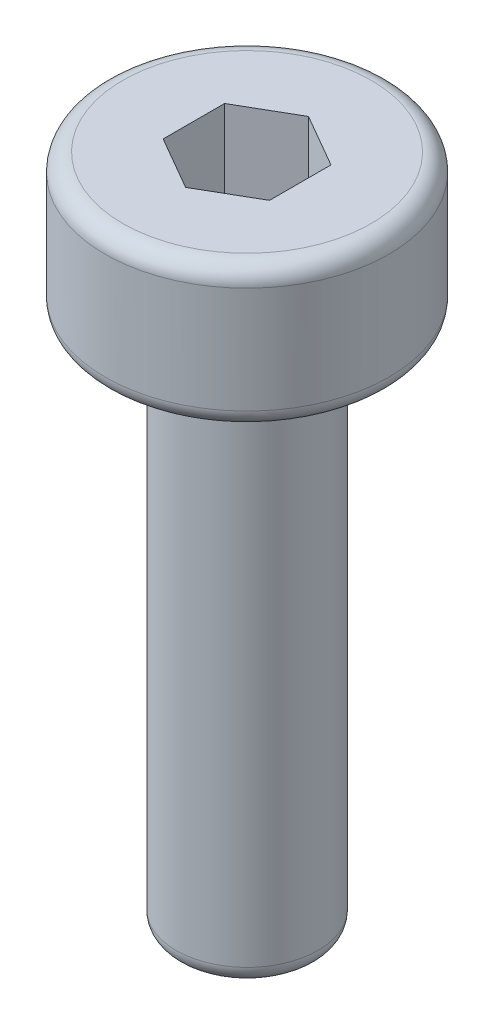
from build123d import *

# Parameters (mm, degrees)
CORTE_EXTRUS_O1_DEPTH = 6
FILETE1_R             = 0.5


with BuildPart() as part:
    # Esboço1 → Revolução1 (revolve)
    with BuildSketch(Plane.XY):
        Polygon((0, -9.5), (0, 9.5), (-4, 9.5), (-4, 5.5), (-2, 5.5), (-2, -9.5), align=None)
    revolve(axis=Axis((0, -9.5, 0), (0, 1, 0)))

    # Esboço2 → Corte-extrusão1 (cut)
    with BuildSketch(Plane(origin=(0, 9.5, 0), x_dir=(1, 0, 0), z_dir=(0, 1, 0))):
        Polygon((1.5, -0.866025404), (1.5, 0.866025404), (0, 1.732050808), (-1.5, 0.866025404), (-1.5, -0.866025404), (0, -1.732050808), align=None)
    extrude(amount=-CORTE_EXTRUS_O1_DEPTH, mode=Mode.SUBTRACT)

    # Filete1
    filete1_edges = [part.edges().sort_by_distance(p)[0] for p in [
        (0.75, 3.5, 1.299038106),
        (-0.75, 3.5, 1.299038106),
        (-1.5, 3.5, 0),
        (-0.75, 3.5, -1.299038106),
        (0.75, 3.5, -1.299038106),
        (1.5, 3.5, 0),
        (2, -9.5, 0),
        (2, 5.5, 0),
        (4, 5.5, 0),
        (4, 9.5, 0),
    ]]
    fillet(filete1_edges, radius=FILETE1_R)


solid = part.part
